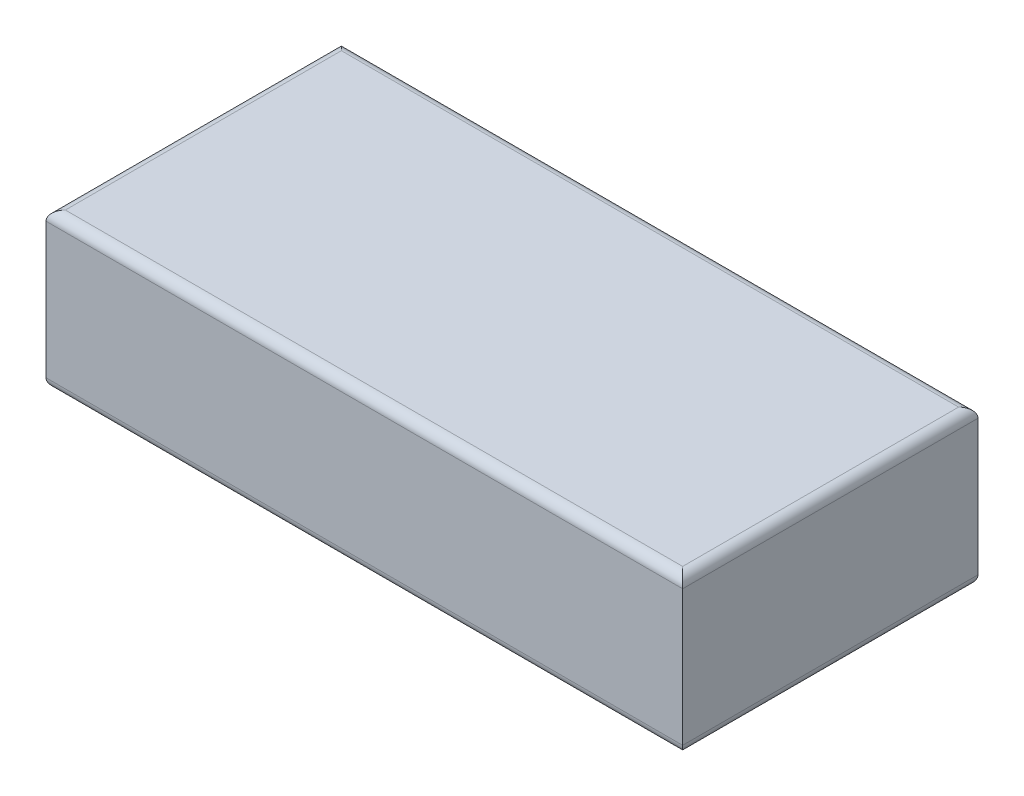
from build123d import *

# Parameters (mm, degrees)
SKETCH1_W           = 263
SKETCH1_H           = 122
BOSS_EXTRUDE1_DEPTH = 64
FILLET1_R           = 4


with BuildPart() as part:
    # Sketch1 → Boss-Extrude1 (new body)
    with BuildSketch(Plane(origin=(0, 0, 0), x_dir=(1, 0, 0), z_dir=(0, 1, 0))):
        with Locations((131.5, 61)):
            Rectangle(SKETCH1_W, SKETCH1_H)
    extrude(amount=BOSS_EXTRUDE1_DEPTH)

    # Fillet1
    fillet1_edges = [part.edges().sort_by_distance(p)[0] for p in [
        (263, 64, -61),
        (131.5, 64, -122),
        (0, 64, -61),
        (131.5, 0, -122),
        (263, 0, -61),
        (131.5, 0, 0),
        (0, 0, -61),
        (131.5, 64, 0),
    ]]
    fillet(fillet1_edges, radius=FILLET1_R)


solid = part.part
